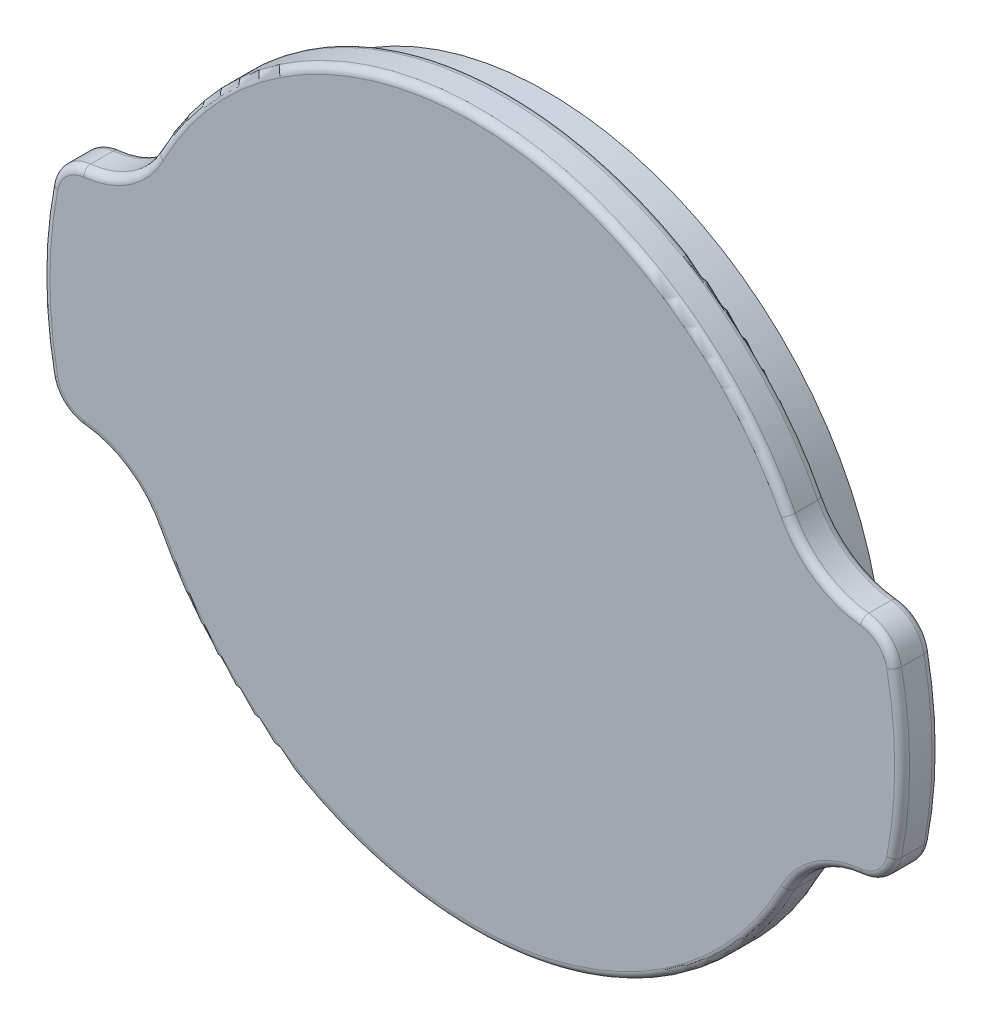
from build123d import *

# Parameters (mm, degrees)
HOPPERTANKCOVER_R      = 95
BOSS_EXTRUDE1_DEPTH    = 10
HOPPERTANKCOVERLIP_R   = 89.9
HOPPERTANKCOVERLIP_R_2 = 85
BOSS_EXTRUDE2_DEPTH    = 10
BOSS_EXTRUDE3_DEPTH    = 10
FILLET1_R              = 25
FILLET3_R              = 10
FILLET4_R              = 2


with BuildPart() as part:
    # hopperTankCover → Boss-Extrude1 (new body)
    with BuildSketch(Plane.XY):
        Circle(HOPPERTANKCOVER_R)
    extrude(amount=BOSS_EXTRUDE1_DEPTH)

    # hopperTankCoverLip → Boss-Extrude2 (add)
    with BuildSketch(Plane(origin=(0, 0, 0), x_dir=(-1, 0, 0), z_dir=(0, 0, -1))):
        Circle(HOPPERTANKCOVERLIP_R)
        Circle(HOPPERTANKCOVERLIP_R_2, mode=Mode.SUBTRACT)
    extrude(amount=BOSS_EXTRUDE2_DEPTH)

    # hopperTankCoverHandle → Boss-Extrude3 (add)
    with BuildSketch(Plane.XY.offset(10)):
        with BuildLine():
            Line((-111.018016556, 30), (-90.138781887, 30))
            ThreePointArc((-90.138781887, 30), (-95, 0), (-90.138781887, -30))
            Line((-90.138781887, -30), (-111.018016556, -30))
            ThreePointArc((-111.018016556, -30), (-115, 0), (-111.018016556, 30))
        make_face()
        with BuildLine():
            Line((111.018016556, -30), (90.138781887, -30))
            ThreePointArc((90.138781887, -30), (95, 0), (90.138781887, 30))
            Line((90.138781887, 30), (111.018016556, 30))
            ThreePointArc((111.018016556, 30), (115, 0), (111.018016556, -30))
        make_face()
    extrude(amount=-BOSS_EXTRUDE3_DEPTH)

    # Fillet1
    fillet1_edges = [part.edges().sort_by_distance(p)[0] for p in [
        (90.138781887, -30, 5),
        (90.138781887, 30, 5),
        (-90.138781887, 30, 5),
        (-90.138781887, -30, 5),
    ]]
    fillet(fillet1_edges, radius=FILLET1_R)

    # Fillet3
    fillet3_edges = [part.edges().sort_by_distance(p)[0] for p in [
        (-111.018016556, -30, 5),
        (-111.018016556, 30, 5),
        (111.018016556, 30, 5),
        (111.018016556, -30, 5),
    ]]
    fillet(fillet3_edges, radius=FILLET3_R)

    # Fillet4
    fillet4_edges = [part.edges().sort_by_distance(p)[0] for p in [
        (0, -95, 10),
        (0, -95, 0),
        (0, 95, 0),
        (0, 95, 10),
        (92.557457302, -34.353027067, 10),
        (92.557457302, 34.353027067, 0),
        (-92.557457302, 34.353027067, 10),
        (-92.557457302, -34.353027067, 0),
        (-115, 0, 10),
        (-115, 0, 0),
        (92.557457302, 34.353027067, 10),
        (-92.557457302, -34.353027067, 10),
        (115, 0, 10),
        (109.786778713, -27.569140744, 10),
        (109.786778713, 27.569140744, 10),
        (-109.786778713, 27.569140744, 10),
        (-109.786778713, -27.569140744, 10),
        (115, 0, 0),
        (92.557457302, -34.353027067, 0),
        (-92.557457302, 34.353027067, 0),
        (109.786778713, -27.569140744, 0),
        (109.786778713, 27.569140744, 0),
        (-109.786778713, 27.569140744, 0),
        (-109.786778713, -27.569140744, 0),
    ]]
    fillet(fillet4_edges, radius=FILLET4_R)


solid = part.part
